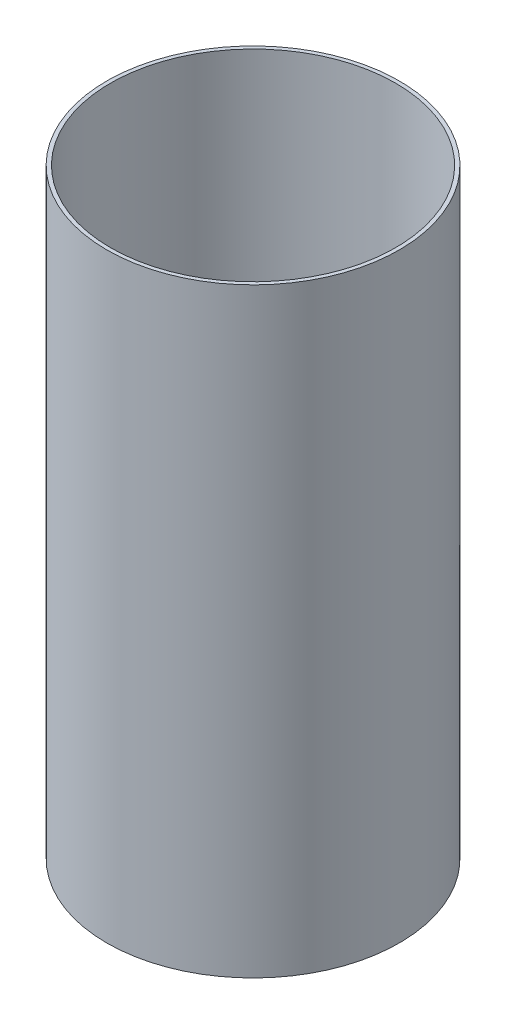
from build123d import *

# Parameters (mm, degrees)
SKETCH1_R           = 49.53
SKETCH1_R_2         = 48.26
BOSS_EXTRUDE1_DEPTH = 203.2


with BuildPart() as part:
    # Sketch1 → Boss-Extrude1 (new body)
    with BuildSketch(Plane(origin=(0, 0, 0), x_dir=(1, 0, 0), z_dir=(0, 1, 0))):
        Circle(SKETCH1_R)
        Circle(SKETCH1_R_2, mode=Mode.SUBTRACT)
    extrude(amount=BOSS_EXTRUDE1_DEPTH)


solid = part.part
